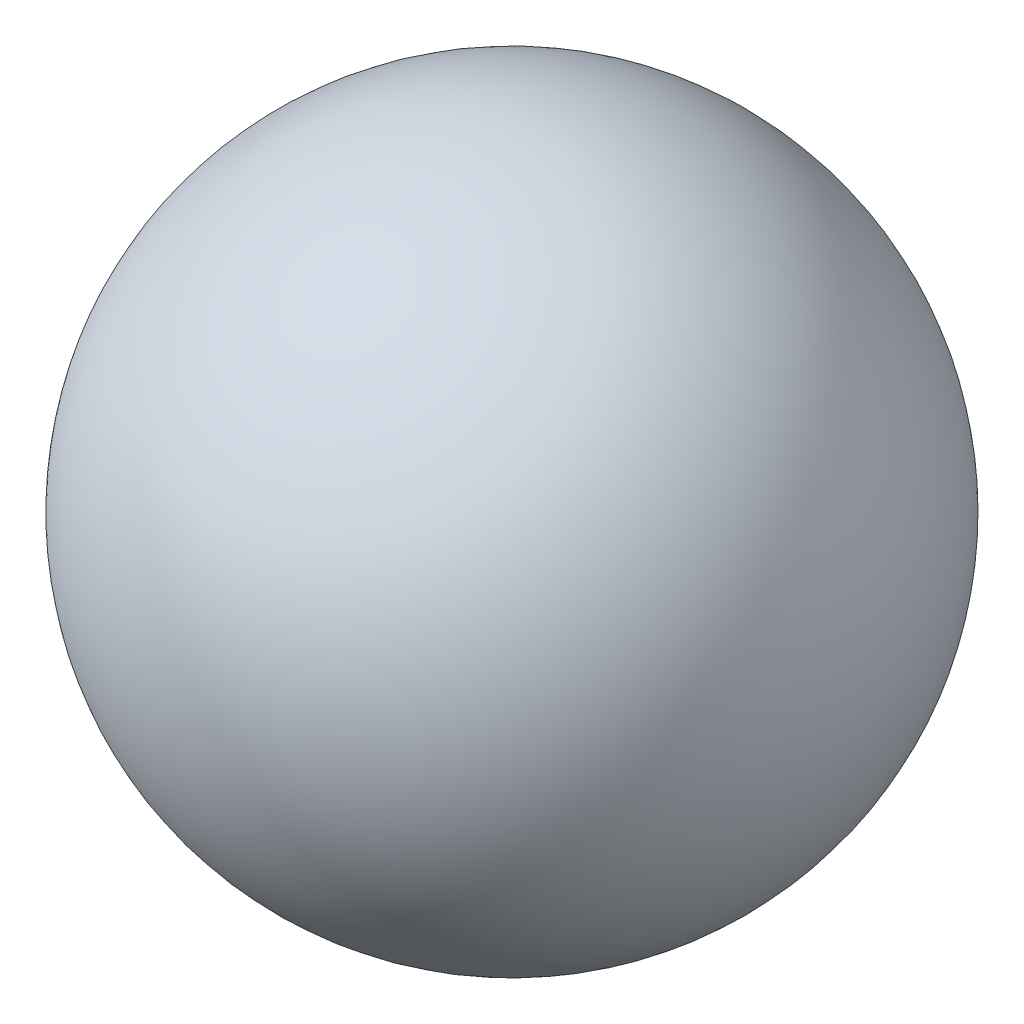
from build123d import *


with BuildPart() as part:
    # Sketch1 → Revolve1 (revolve)
    with BuildSketch(Plane(origin=(0, 0, 0), x_dir=(0, 0, -1), z_dir=(1, 0, 0))):
        with BuildLine():
            Line((-60.950875279, 109.797421805), (1.373540851, 68.076118445))
            ThreePointArc((1.373540851, 68.076118445), (-8.928015534, 120.09897819), (-60.950875279, 109.797421805))
        make_face()
    revolve(axis=Axis((0, 109.797421805, 60.950875279), (0, -0.556284045, -0.830992215)))


solid = part.part
